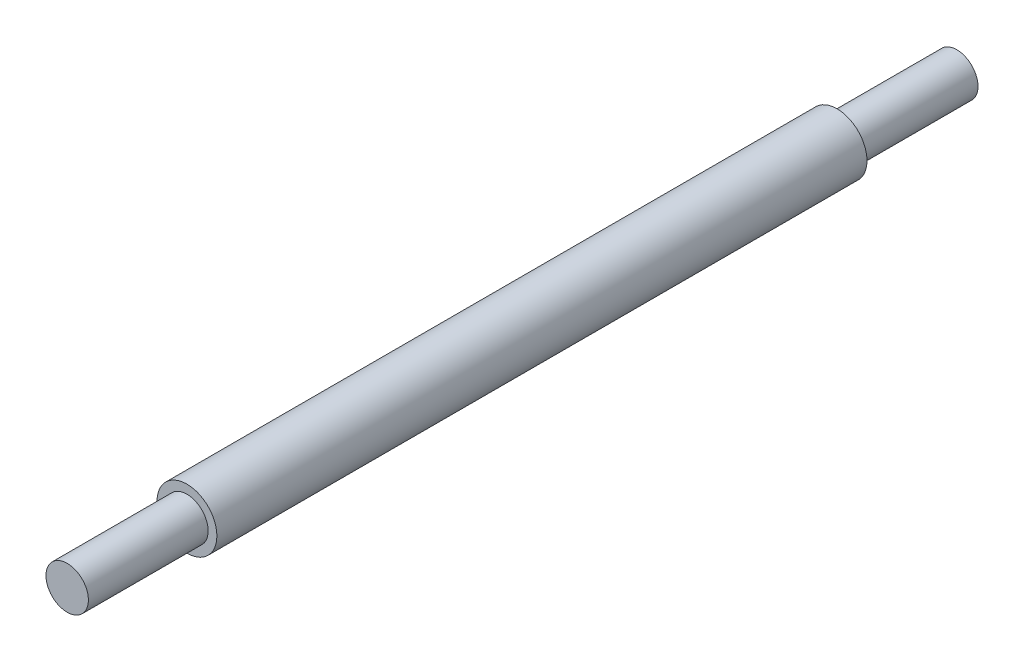
from build123d import *

# Parameters (mm, degrees)
SKETCH2_R      = 2.778125
EXTRUDE1_DEPTH = 30.1625
SKETCH3_R      = 1.9685
EXTRUDE2_DEPTH = 11.1125
SKETCH4_R      = 1.9685
EXTRUDE3_DEPTH = 11.1125


with BuildPart() as part:
    # Sketch2 → Extrude1 (new body, symmetric)
    with BuildSketch(Plane.XY):
        Circle(SKETCH2_R)
    extrude(amount=EXTRUDE1_DEPTH, both=True)

    # Sketch3 → Extrude2 (add)
    with BuildSketch(Plane.XY.offset(30.1625)):
        Circle(SKETCH3_R)
    extrude(amount=EXTRUDE2_DEPTH)

    # Sketch4 → Extrude3 (add)
    with BuildSketch(Plane(origin=(0, 0, -30.1625), x_dir=(-1, 0, 0), z_dir=(0, 0, -1))):
        Circle(SKETCH4_R)
    extrude(amount=EXTRUDE3_DEPTH)


solid = part.part
